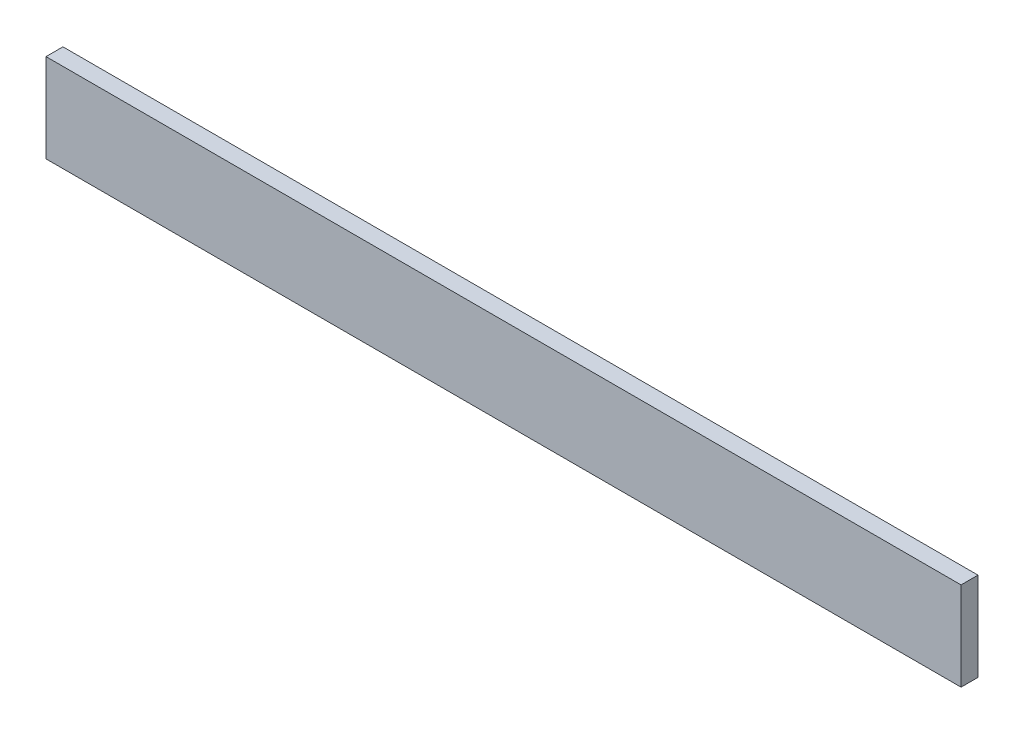
from build123d import *

# Parameters (mm, degrees)
MODEL_W             = 162
MODEL_H             = 15.682742453
BOSS_EXTRUDE1_DEPTH = 3


with BuildPart() as part:
    # Model → Boss-Extrude1 (new body)
    with BuildSketch(Plane.XY):
        with Locations((90.507461859, 15.869834704)):
            Rectangle(MODEL_W, MODEL_H)
    extrude(amount=BOSS_EXTRUDE1_DEPTH)


solid = part.part
